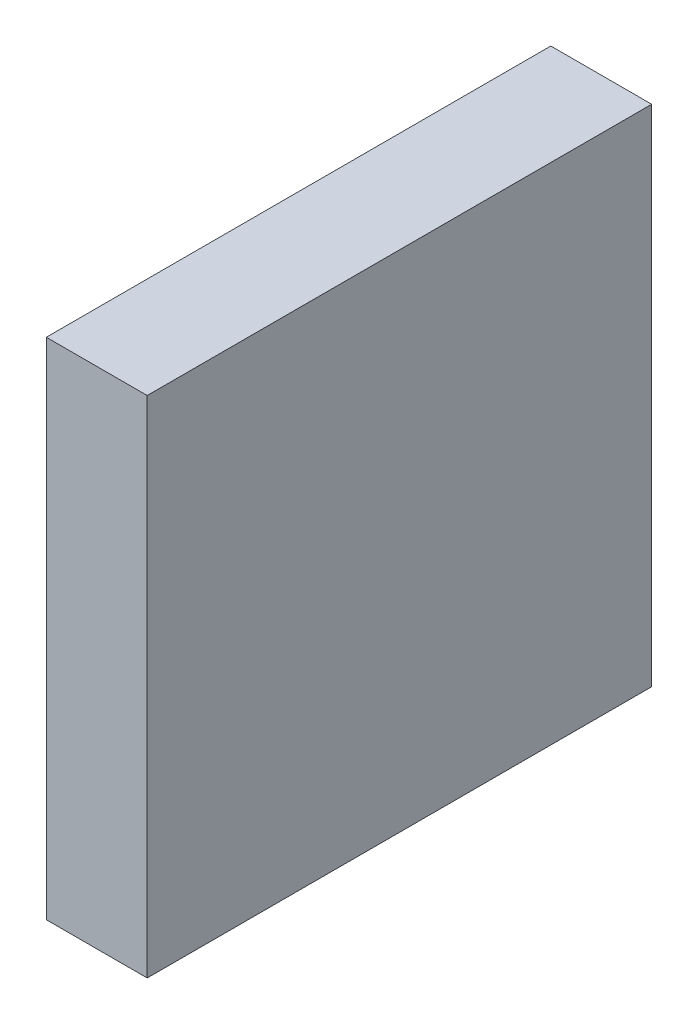
from build123d import *

# Parameters (mm, degrees)
SZKIC1_W                    = 12
SZKIC1_H                    = 60
DODANIE_WYCI_GNI_CIE1_DEPTH = 60


with BuildPart() as part:
    # Szkic1 → Dodanie-wyciągnięcie1 (new body)
    with BuildSketch(Plane.XY):
        with Locations((-22.031083758, 30.251350229)):
            Rectangle(SZKIC1_W, SZKIC1_H)
    extrude(amount=DODANIE_WYCI_GNI_CIE1_DEPTH)


solid = part.part
